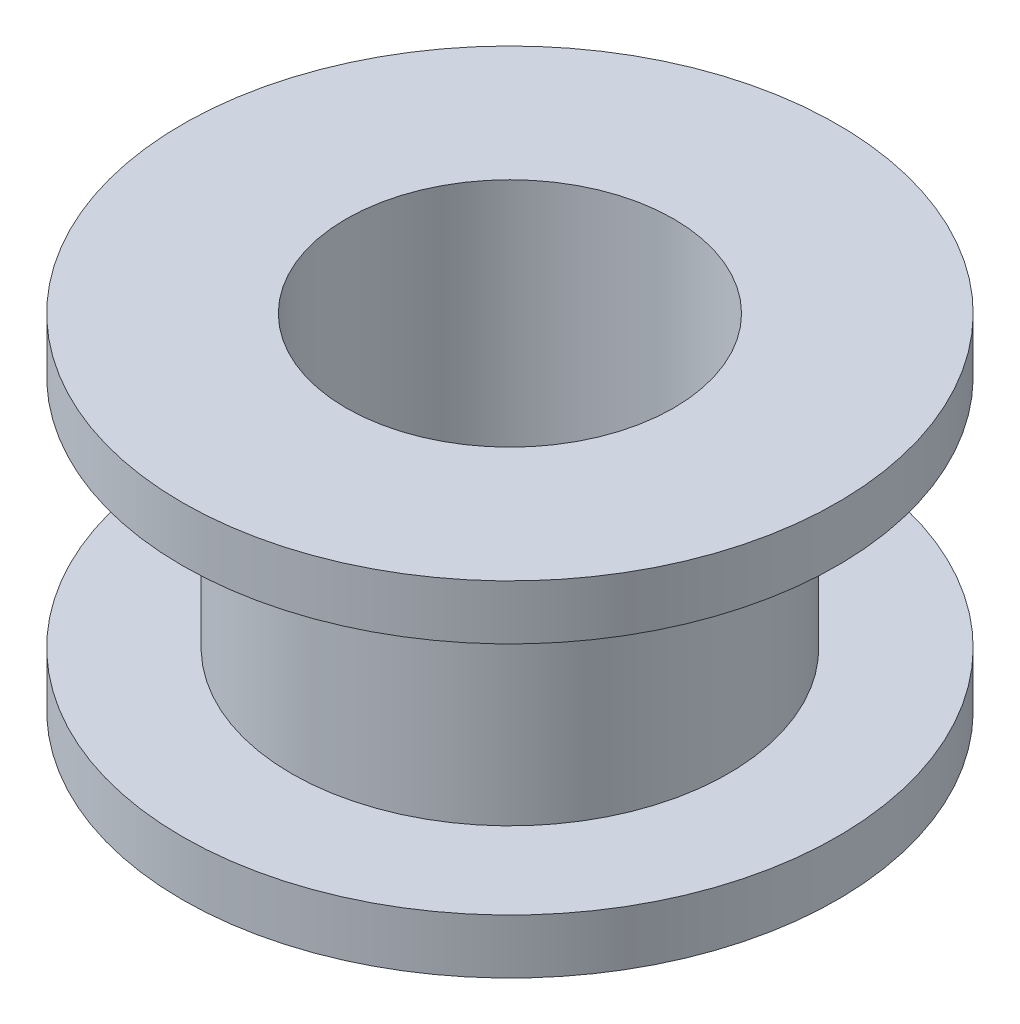
from build123d import *

# Parameters (mm, degrees)
SKETCH1_R           = 6
SKETCH1_R_2         = 4.5
BOSS_EXTRUDE1_DEPTH = 3.225
SKETCH2_R           = 9
SKETCH2_R_2         = 4.5
BOSS_EXTRUDE2_DEPTH = 1.5


with BuildPart() as part:
    # Sketch1 → Boss-Extrude1 (new body, symmetric)
    with BuildSketch(Plane(origin=(0, 0, 0), x_dir=(1, 0, 0), z_dir=(0, 1, 0))):
        Circle(SKETCH1_R)
        Circle(SKETCH1_R_2, mode=Mode.SUBTRACT)
    extrude(amount=BOSS_EXTRUDE1_DEPTH, both=True)

    # Sketch2 → Boss-Extrude2 (add)
    with BuildSketch(Plane(origin=(0, 3.225, 0), x_dir=(1, 0, 0), z_dir=(0, 1, 0))):
        Circle(SKETCH2_R)
        Circle(SKETCH2_R_2, mode=Mode.SUBTRACT)
    boss_extrude2 = extrude(amount=BOSS_EXTRUDE2_DEPTH)

    # Mirror1: Boss-Extrude2 across plane
    add(boss_extrude2.mirror(Plane.ZX))


solid = part.part
